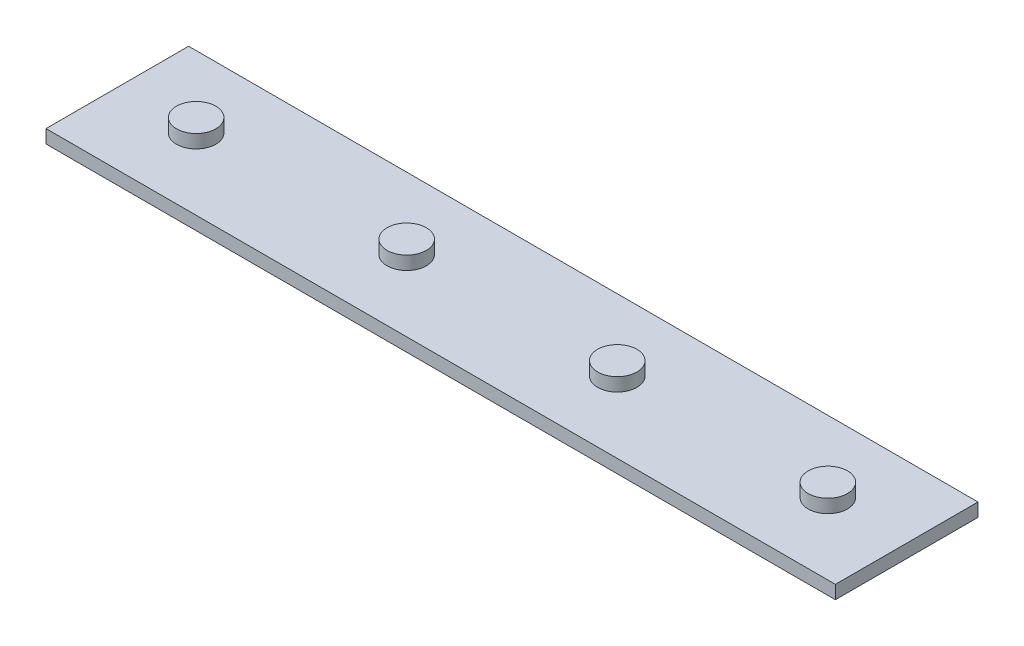
from build123d import *

# Parameters (mm, degrees)
SKETCH1_W           = 281.158896912
SKETCH1_H           = 50.8
BOSS_EXTRUDE1_DEPTH = 9.525
SKETCH2_OUTSIDE_W   = 340.332
SKETCH2_OUTSIDE_H   = 109.974
SKETCH2_OUTSIDE_R   = 7
CUT_EXTRUDE1_DEPTH  = 4.7625


with BuildPart() as part:
    # Sketch1 → Boss-Extrude1 (new body)
    with BuildSketch(Plane(origin=(0, 0, 0), x_dir=(1, 0, 0), z_dir=(0, 1, 0))):
        Rectangle(SKETCH1_W, SKETCH1_H)
    extrude(amount=BOSS_EXTRUDE1_DEPTH)

    # Sketch2 outside → Cut-Extrude1 (cut)
    with BuildSketch(Plane(origin=(0, 9.525, 0), x_dir=(1, 0, 0), z_dir=(0, 1, 0))):
        Rectangle(SKETCH2_OUTSIDE_W, SKETCH2_OUTSIDE_H)
        with Locations((-112.5, 0)):
            Circle(SKETCH2_OUTSIDE_R, mode=Mode.SUBTRACT)
        with Locations((-37.5, 0)):
            Circle(SKETCH2_OUTSIDE_R, mode=Mode.SUBTRACT)
        with Locations((37.5, 0)):
            Circle(SKETCH2_OUTSIDE_R, mode=Mode.SUBTRACT)
        with Locations((112.5, 0)):
            Circle(SKETCH2_OUTSIDE_R, mode=Mode.SUBTRACT)
    extrude(amount=-CUT_EXTRUDE1_DEPTH, mode=Mode.SUBTRACT)


solid = part.part
